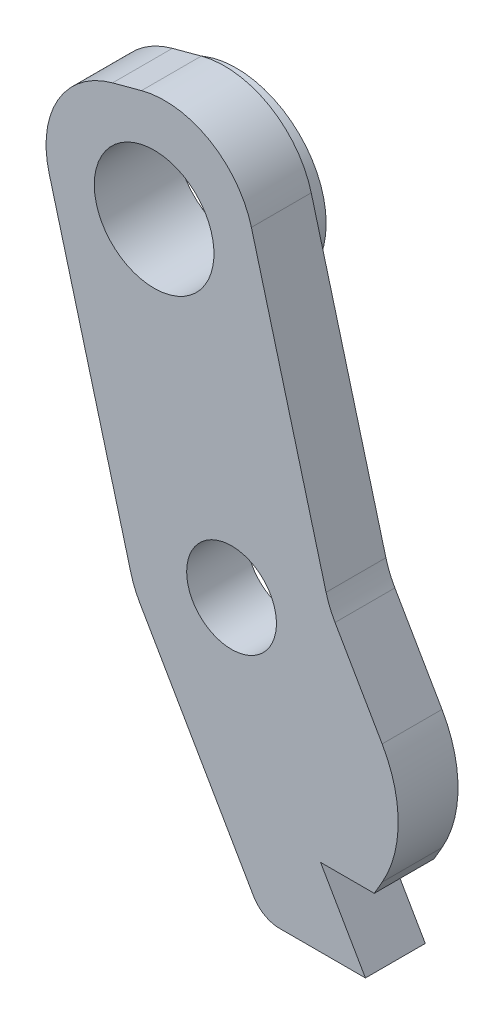
from build123d import *

# Parameters (mm, degrees)
SKETCH_1_R      = 2
SKETCH_1_R_2    = 1.5
EXTRUDE_1_DEPTH = 2
FILLET_1_R      = 3
FILLET_2_R      = 4
FILLET_3_R      = 1
SKETCH_2_R      = 3
SKETCH_2_R_2    = 2
EXTRUDE_2_DEPTH = 0.75


with BuildPart() as part:
    # 草图1 → 凸台-拉伸1 (new body)
    with BuildSketch(Plane(origin=(0, 0, -37.252464054), x_dir=(0.999999999, -4.5024e-05, 0), z_dir=(0, 0, 1))):
        Polygon((-10.738945167, 10.350396652), (-14.113721921, 22.945234964), (-20.875202705, 21.133501648), (-17.261865242, 7.64834265), (-12.97599562, 0.225770523), (-9.524857048, 0.225770523), (-11.024974023, 2.823779195), (-9.229747105, 2.823860024), (-7.811543717, 5.280515782), align=None)
        with Locations((-16.588595655, 18.658627914)):
            Circle(SKETCH_1_R, mode=Mode.SUBTRACT)
        with Locations((-14.000405204, 8.999369651)):
            Circle(SKETCH_1_R_2, mode=Mode.SUBTRACT)
    extrude(amount=EXTRUDE_1_DEPTH)

    # 圆角1
    fillet_1_edges = [part.edges().sort_by_distance(p)[0] for p in [
        (-10.738479137, 10.350880155, -36.252464054),
        (-14.112688814, 22.945870401, -36.252464054),
        (-20.874251163, 21.134441518, -36.252464054),
        (-17.261520863, 7.649119845, -36.252464054),
    ]]
    fillet(fillet_1_edges, radius=FILLET_1_R)

    # 圆角2
    fillet_2_edges = [part.edges().sort_by_distance(p)[0] for p in [
        (-7.811305958, 5.280867486, -36.252464054),
    ]]
    fillet(fillet_2_edges, radius=FILLET_2_R)

    # 圆角3
    fillet_3_edges = [part.edges().sort_by_distance(p)[0] for p in [
        (-12.975985442, 0.226354757, -36.252464054),
    ]]
    fillet(fillet_3_edges, radius=FILLET_3_R)

    # 草图2 → 凸台-拉伸2 (add)
    with BuildSketch(Plane(origin=(-0.25104956, -0.068074204, -37.252464054), x_dir=(1, 0, 0), z_dir=(0, 0, 1))):
        with Locations((-16.336705988, 18.727448988)):
            Circle(SKETCH_2_R)
        with Locations((-16.336705988, 18.727448988)):
            Circle(SKETCH_2_R_2, mode=Mode.SUBTRACT)
    extrude(amount=-EXTRUDE_2_DEPTH)


solid = part.part
